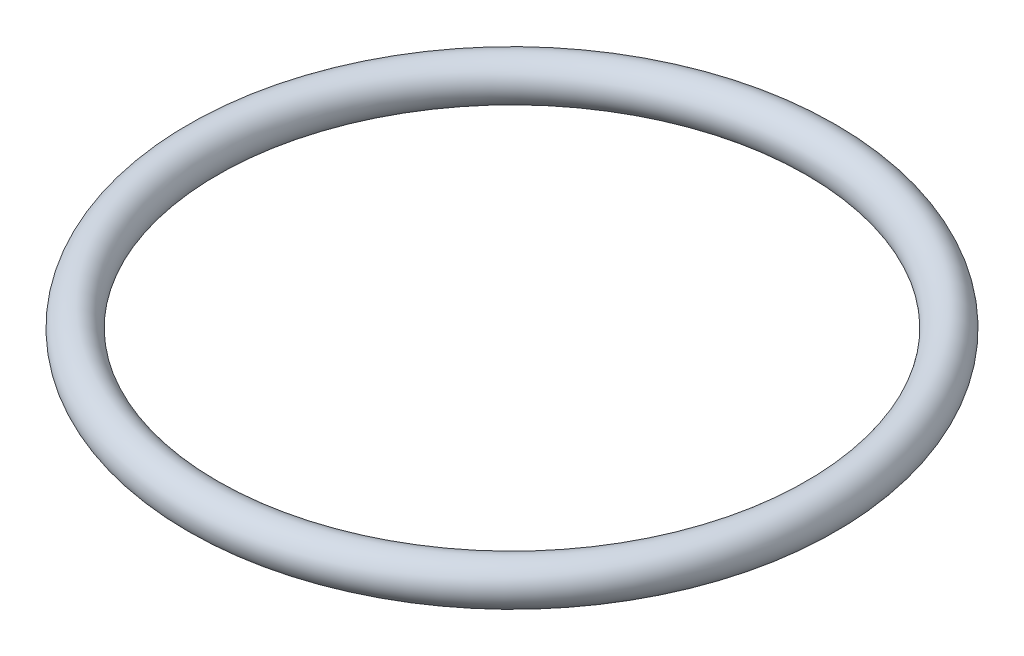
from build123d import *

# Parameters (mm, degrees)
SKETCH1_R = 10


with BuildPart() as part:
    # Sketch1 → Revolve1 (revolve)
    with BuildSketch(Plane.XY):
        with Locations((-150, 0)):
            Circle(SKETCH1_R)
    revolve(axis=Axis((0, 52.071428571, 0), (0, -1, 0)))


solid = part.part
